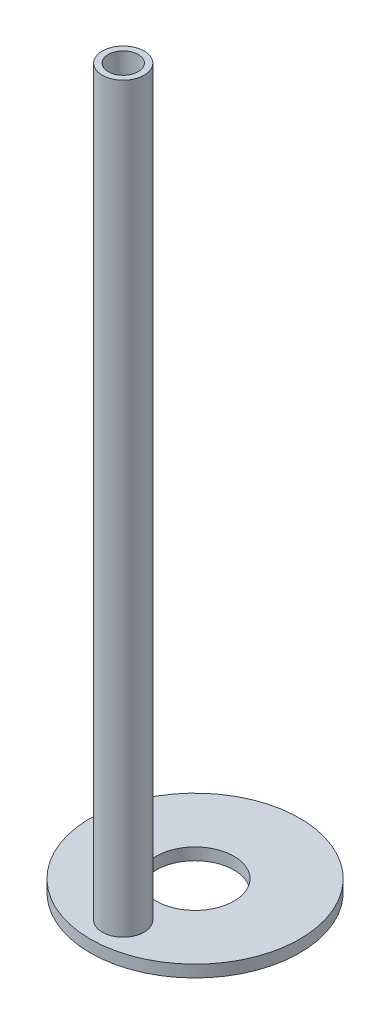
from build123d import *

# Parameters (mm, degrees)
SKETCH2_R          = 17.5
SKETCH2_R_2        = 6.5
PLATE_DEPTH        = 1
SKETCH2_4_R        = 3.5
ROD_DEPTH          = 125
SKETCH3_R          = 2.5
CUT_EXTRUDE1_DEPTH = 129.407554295


with BuildPart() as part:
    # Sketch2 → Plate (new, symmetric)
    with BuildSketch(Plane(origin=(0, 0, 0), x_dir=(1, 0, 0), z_dir=(0, 1, 0))):
        Circle(SKETCH2_R)
        Circle(SKETCH2_R_2, mode=Mode.SUBTRACT)
    extrude(amount=PLATE_DEPTH, both=True)

    # Sketch2_4 → Rod (add)
    with BuildSketch(Plane(origin=(0, 0, 0), x_dir=(1, 0, 0), z_dir=(0, 1, 0))):
        with Locations((0, -12)):
            Circle(SKETCH2_4_R)
    extrude(amount=ROD_DEPTH)

    # Sketch3 → Cut-Extrude1 (cut, through all)
    with BuildSketch(Plane(origin=(0, 125, 0), x_dir=(1, 0, 0), z_dir=(0, 1, 0))):
        with Locations((0, -12)):
            Circle(SKETCH3_R)
    extrude(amount=-CUT_EXTRUDE1_DEPTH, mode=Mode.SUBTRACT)


solid = part.part
